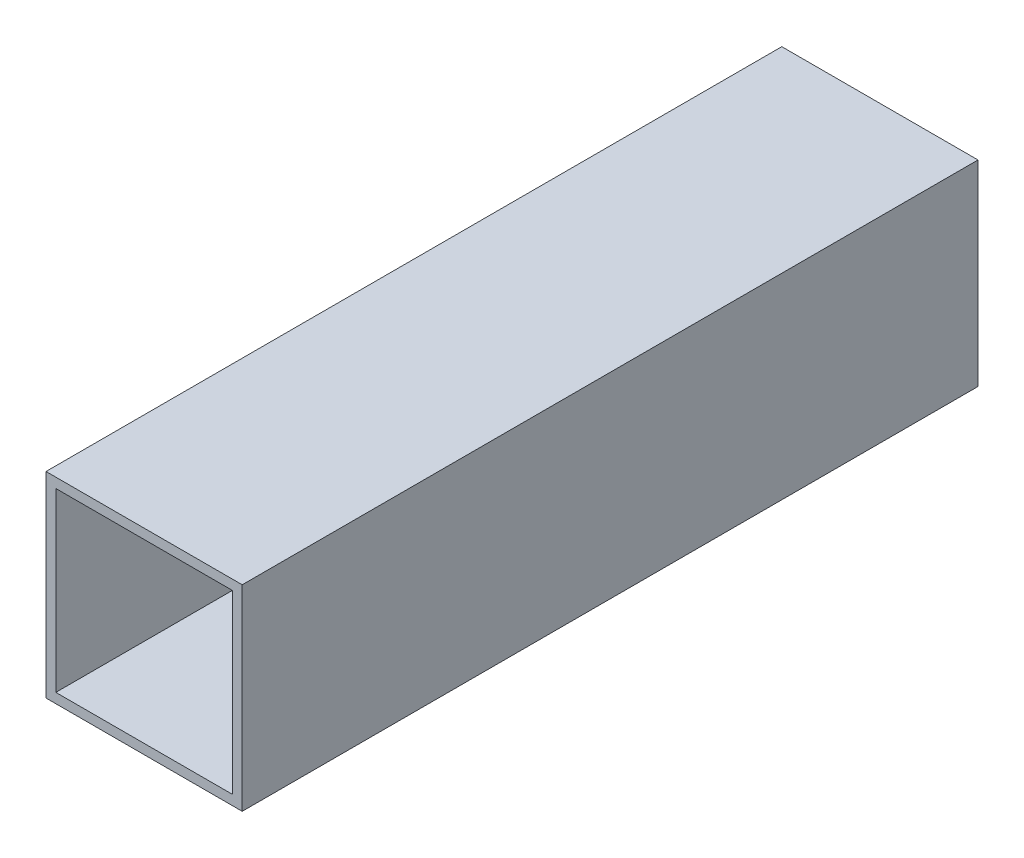
from build123d import *

# Parameters (mm, degrees)
SKETCH1_W           = 100
SKETCH1_H           = 100
SKETCH1_W_2         = 90
SKETCH1_H_2         = 90
BOSS_EXTRUDE1_DEPTH = 187.5


with BuildPart() as part:
    # Sketch1 → Boss-Extrude1 (new body, symmetric)
    with BuildSketch(Plane.XY):
        Rectangle(SKETCH1_W, SKETCH1_H)
        Rectangle(SKETCH1_W_2, SKETCH1_H_2, mode=Mode.SUBTRACT)
    extrude(amount=BOSS_EXTRUDE1_DEPTH, both=True)


solid = part.part
